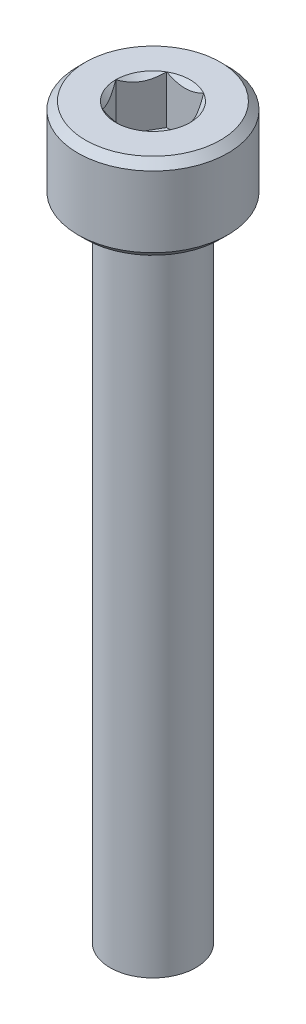
from build123d import *

# Parameters (mm, degrees)
SKETCH1_R           = 3.5
BOSS_EXTRUDE1_DEPTH = 4
CUT_EXTRUDE1_DEPTH  = 2.25
CHAMFER1_SIZE       = 0.35
SKETCH_1_R          = 2
EXTRUDE_1_DEPTH     = 30


with BuildPart() as part:
    # Sketch1 → Boss-Extrude1 (new body)
    with BuildSketch(Plane(origin=(0, 0, 0), x_dir=(1, 0, 0), z_dir=(0, 1, 0))):
        with Locations(Location((0, 0, 0), (0, 0, 270))):
            Circle(SKETCH1_R)
    extrude(amount=BOSS_EXTRUDE1_DEPTH)

    # Sketch2 → Cut-Extrude1 (cut)
    with BuildSketch(Plane(origin=(0, 4, 0), x_dir=(1, 0, 0), z_dir=(0, 1, 0))):
        Polygon((0.866025404, 1.5), (-0.866025404, 1.5), (-1.732050808, 0), (-0.866025404, -1.5), (0.866025404, -1.5), (1.732050808, 0), align=None)
    extrude(amount=-CUT_EXTRUDE1_DEPTH, mode=Mode.SUBTRACT)

    # Cut-Extrude2 cone 1 section (through the dimple's axis) → Cut-Extrude2 (revolve, cut)
    with BuildSketch(Plane(origin=(0, 4, 0), x_dir=(0, 0, 1), z_dir=(1, 0, 0))):
        Polygon((0, 0), (1.732050808, 0), (0, 1.732050808), align=None)
    revolve(axis=Axis((0, 4, 0), (0, -1, 0)), mode=Mode.SUBTRACT)

    # Chamfer1
    chamfer1_edges = [part.edges().sort_by_distance(p)[0] for p in [
        (0, 0, -3.5),
        (0, 4, -3.5),
    ]]
    chamfer(chamfer1_edges, length=CHAMFER1_SIZE)

    # 草图1 → 凸台-拉伸1 (add)
    with BuildSketch(Plane(origin=(0, 0, 0), x_dir=(-1, 0, 0), z_dir=(0, -1, 0))):
        with Locations(Location((0, 0, 0), (0, 0, 90))):
            Circle(SKETCH_1_R)
    extrude(amount=EXTRUDE_1_DEPTH)


solid = part.part
